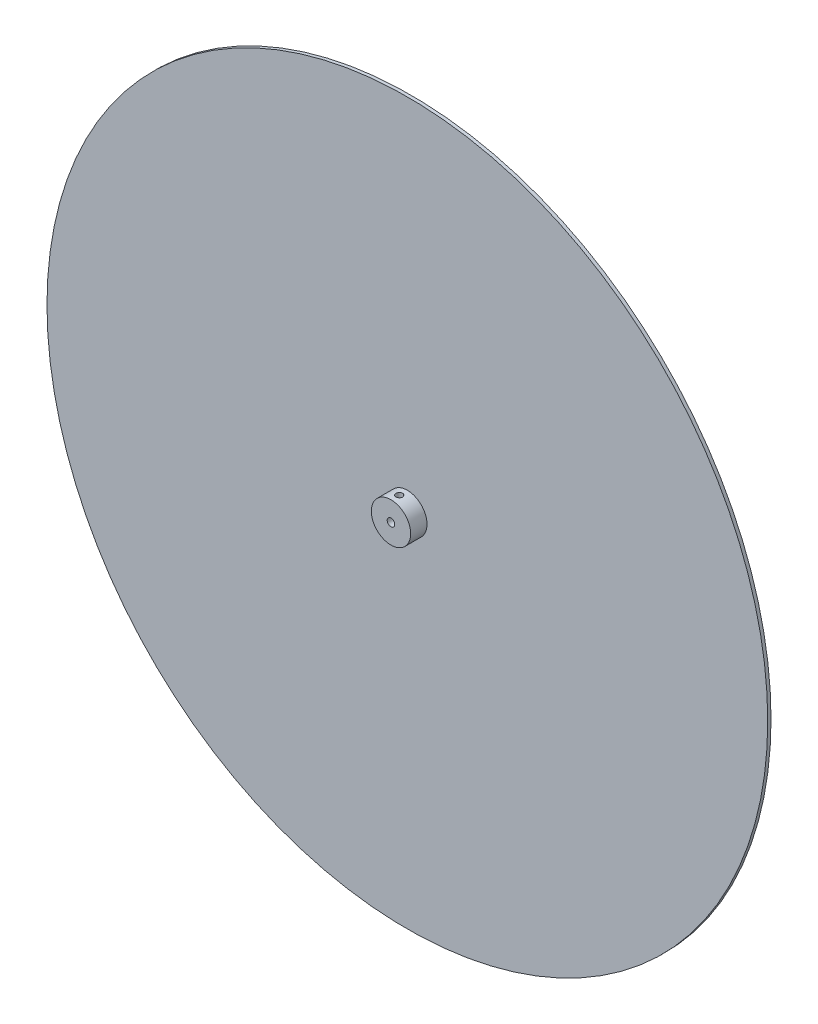
from build123d import *

# Parameters (mm, degrees)
SKETCH_1_R           = 110
SKETCH_1_R_2         = 1.15
EXTRUDE_1_DEPTH      = 1
SKETCH_2_R           = 6
SKETCH_2_R_2         = 1.15
EXTRUDE_2_DEPTH      = 5
EXTRUDE_2_DEPTH_BACK = 6
SKETCH_3_R           = 1
CUT_EXTRUDE_1_DEPTH  = 25


with BuildPart() as part:
    # 草图1 → 凸台-拉伸1 (new body)
    with BuildSketch(Plane.XY):
        Circle(SKETCH_1_R)
        Circle(SKETCH_1_R_2, mode=Mode.SUBTRACT)
    extrude(amount=EXTRUDE_1_DEPTH)

    # 草图2 → 凸台-拉伸2 (add, two sides)
    with BuildSketch(Plane(origin=(0, 0, 0), x_dir=(-1, 0, 0), z_dir=(0, 0, -1))) as extrude_2_sk:
        Circle(SKETCH_2_R)
        Circle(SKETCH_2_R_2, mode=Mode.SUBTRACT)
    extrude(amount=EXTRUDE_2_DEPTH)
    extrude(extrude_2_sk.sketch, amount=-EXTRUDE_2_DEPTH_BACK)

    # 草图3 → 切除-拉伸1 (cut, symmetric)
    with BuildSketch(Plane(origin=(0, 0, 0), x_dir=(1, 0, 0), z_dir=(0, 1, 0))):
        with Locations((0, 2.5)):
            Circle(SKETCH_3_R)
        with Locations((0, -3.5)):
            Circle(SKETCH_3_R)
    extrude(amount=CUT_EXTRUDE_1_DEPTH, both=True, mode=Mode.SUBTRACT)


solid = part.part
